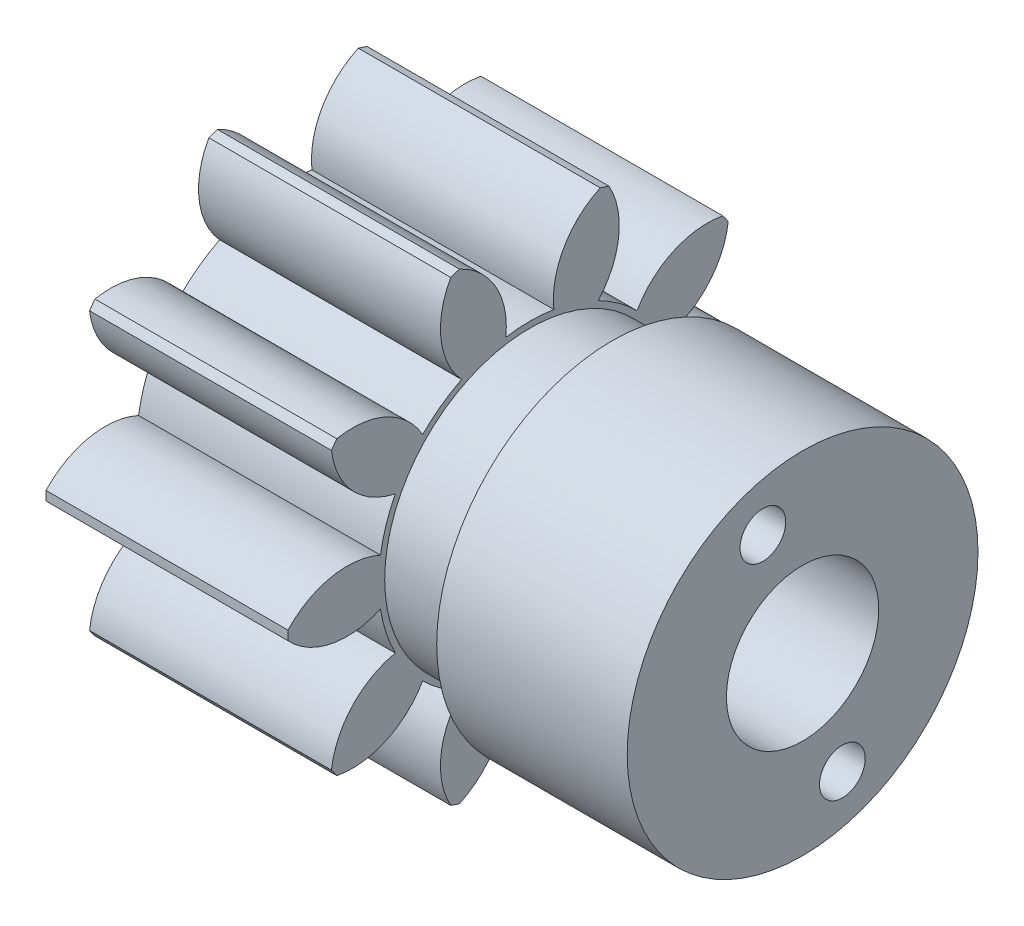
from build123d import *

# Parameters (mm, degrees)
BASPROSKE_W              = 12.7
BASPROSKE_H              = 12.7
TOOTHCUT_DEPTH           = 22.997045256
TEETHCUTS_COUNT          = 10
SKETCH15_R               = 7.62
BOSS_EXTRUDE2_DEPTH      = 4.318
SKETCH8_R                = 9.2075
BOSS_EXTRUDE1_DEPTH      = 10
M2_CLEARANCE_HOLE1_D     = 2.4
M2_CLEARANCE_HOLE1_DEPTH = 10
CIRPATTERN1_COUNT        = 4
SKETCH13_R               = 4
CUT_EXTRUDE1_DEPTH       = 33.232032369
CUT_EXTRUDE1_DEPTH_BACK  = 33.232032369


with BuildPart() as part:
    # BasProSke → Base-Revolve (revolve)
    with BuildSketch(Plane(origin=(0, 0, 0), x_dir=(1, 0, 0), z_dir=(0, 1, 0)), mode=Mode.PRIVATE) as base_revolve_sk:
        with Locations((6.35, 6.35)):
            Rectangle(BASPROSKE_W, BASPROSKE_H)
    revolve(base_revolve_sk.sketch.rotate(Axis((-10, 0, 0), (1, 0, 0)), 180), axis=Axis((-10, 0, 0), (1, 0, 0)))

    # TooCutSke → ToothCut (cut, through all)
    with BuildSketch(Plane(origin=(0, 0, 0), x_dir=(0, 0, -1), z_dir=(1, 0, 0))):
        with BuildLine():
            ThreePointArc((1.261053733, 7.835399804), (0, 7.93623), (-1.261053733, 7.835399804))
            ThreePointArc((-1.261053733, 7.835399804), (-1.789991322, 10.402889218), (-3.729263267, 12.166692264))
            ThreePointArc((-3.729263267, 12.166692264), (0, 12.7254), (3.729263267, 12.166692264))
            ThreePointArc((3.729263267, 12.166692264), (1.789991322, 10.402889218), (1.261053733, 7.835399804))
        make_face()
    toothcut = extrude(amount=TOOTHCUT_DEPTH, mode=Mode.SUBTRACT)

    # TeethCuts: ToothCut ×10 about axis
    teethcuts_axis = Axis((0, 0, 0), (1, 0, 0))
    for i in range(1, TEETHCUTS_COUNT):
        add(toothcut.rotate(teethcuts_axis, i * 360 / TEETHCUTS_COUNT), mode=Mode.SUBTRACT)

    # Sketch15 → Boss-Extrude2 (add)
    with BuildSketch(Plane(origin=(12.7, 0, 0), x_dir=(0, 0, -1), z_dir=(1, 0, 0))):
        with Locations(Location((0, 0, 0), (0, 0, 180))):
            Circle(SKETCH15_R)
    extrude(amount=BOSS_EXTRUDE2_DEPTH)

    # Sketch8 → Boss-Extrude1 (add)
    with BuildSketch(Plane(origin=(17.018, 0, 0), x_dir=(0, 0, -1), z_dir=(1, 0, 0))):
        Circle(SKETCH8_R)
    extrude(amount=BOSS_EXTRUDE1_DEPTH)

    # M2 Clearance Hole1
    with Locations(Plane(origin=(27.018, 0, 0), x_dir=(0, 0, -1), z_dir=(1, 0, 0))):
        with Locations((-2.085864712, 6.419631485)):
            m2_clearance_hole1 = Hole(M2_CLEARANCE_HOLE1_D / 2, depth=M2_CLEARANCE_HOLE1_DEPTH)

    # CirPattern1: M2 Clearance Hole1 ×4 about axis, 2 skipped
    cirpattern1_axis = Axis((27.018, 0, 0), (-1, 0, 0))
    add([m2_clearance_hole1.rotate(cirpattern1_axis, i * 360 / CIRPATTERN1_COUNT) for i in range(1, CIRPATTERN1_COUNT) if i not in (1, 3)], mode=Mode.SUBTRACT)

    # Sketch13 → Cut-Extrude1 (cut, two sides)
    with BuildSketch(Plane.ZY) as cut_extrude1_sk:
        Circle(SKETCH13_R)
    extrude(amount=CUT_EXTRUDE1_DEPTH, mode=Mode.SUBTRACT)
    extrude(cut_extrude1_sk.sketch, amount=-CUT_EXTRUDE1_DEPTH_BACK, mode=Mode.SUBTRACT)


solid = part.part
